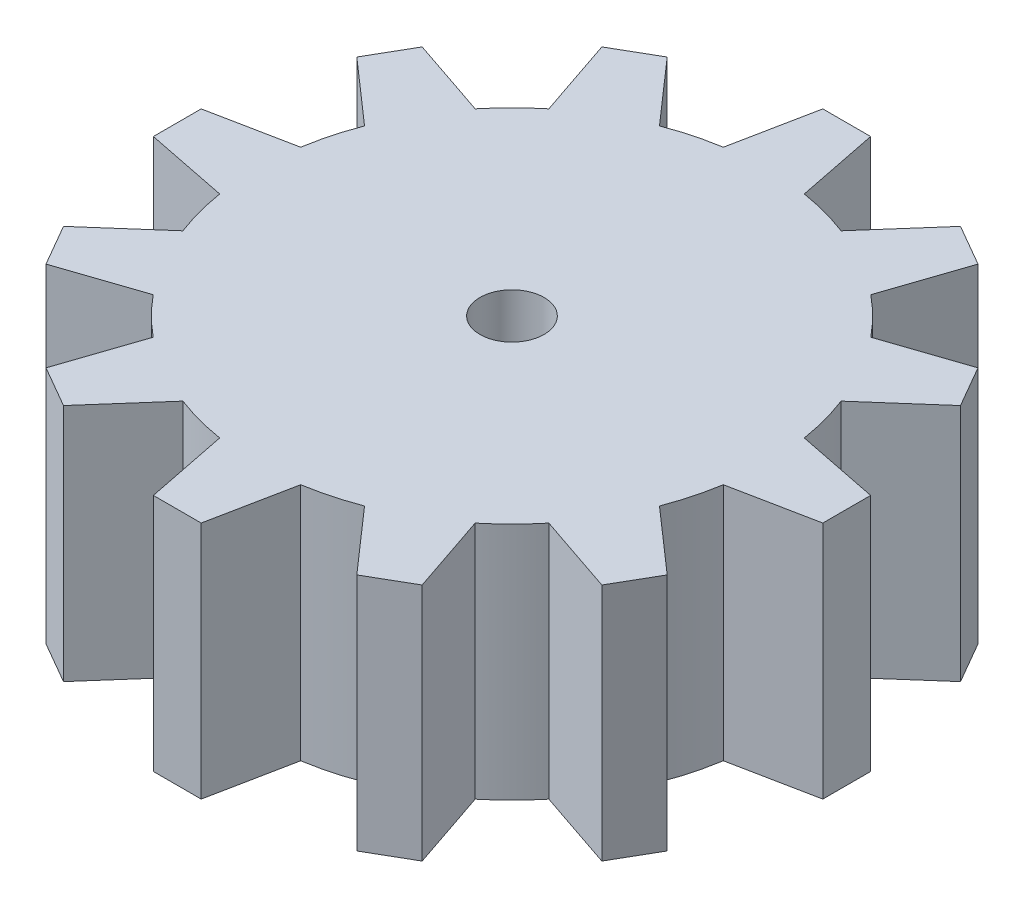
from build123d import *

# Parameters (mm, degrees)
BOSS_EXTRUDE1_DEPTH = 15
CUT_EXTRUDE1_REACH  = 17
SKETCH2_R           = 2.013136899


with BuildPart() as part:
    # Sketch1 → Boss-Extrude1 (new body)
    with BuildSketch(Plane(origin=(0, 0, 0), x_dir=(1, 0, 0), z_dir=(0, 1, 0))):
        with BuildLine():
            Line((-2.540599067, 15.797004665), (-1.5, 21))
            Line((-1.5, 21), (1.5, 21))
            Line((1.5, 21), (2.540599067, 15.797004665))
            ThreePointArc((2.540599067, 15.797004665), (4.141104722, 15.454813221), (5.698279, 14.950906877))
            Line((5.698279, 14.950906877), (9.200961894, 18.936533479))
            Line((9.200961894, 18.936533479), (11.799038106, 17.436533479))
            Line((11.799038106, 17.436533479), (10.098725665, 12.41030781))
            ThreePointArc((10.098725665, 12.41030781), (11.313708499, 11.313708499), (12.41030781, 10.098725665))
            Line((12.41030781, 10.098725665), (17.436533479, 11.799038106))
            Line((17.436533479, 11.799038106), (18.936533479, 9.200961894))
            Line((18.936533479, 9.200961894), (14.950906877, 5.698279))
            ThreePointArc((14.950906877, 5.698279), (15.454813221, 4.141104722), (15.797004665, 2.540599067))
            Line((15.797004665, 2.540599067), (21, 1.5))
            Line((21, 1.5), (21, -1.5))
            Line((21, -1.5), (15.797004665, -2.540599067))
            ThreePointArc((15.797004665, -2.540599067), (15.454813221, -4.141104722), (14.950906877, -5.698279))
            Line((14.950906877, -5.698279), (18.936533479, -9.200961894))
            Line((18.936533479, -9.200961894), (17.436533479, -11.799038106))
            Line((17.436533479, -11.799038106), (12.41030781, -10.098725665))
            ThreePointArc((12.41030781, -10.098725665), (11.313708499, -11.313708499), (10.098725665, -12.41030781))
            Line((10.098725665, -12.41030781), (11.799038106, -17.436533479))
            Line((11.799038106, -17.436533479), (9.200961894, -18.936533479))
            Line((9.200961894, -18.936533479), (5.698279, -14.950906877))
            ThreePointArc((5.698279, -14.950906877), (4.141104722, -15.454813221), (2.540599067, -15.797004665))
            Line((2.540599067, -15.797004665), (1.5, -21))
            Line((1.5, -21), (-1.5, -21))
            Line((-1.5, -21), (-2.540599067, -15.797004665))
            ThreePointArc((-2.540599067, -15.797004665), (-4.141104722, -15.454813221), (-5.698279, -14.950906877))
            Line((-5.698279, -14.950906877), (-9.200961894, -18.936533479))
            Line((-9.200961894, -18.936533479), (-11.799038106, -17.436533479))
            Line((-11.799038106, -17.436533479), (-10.098725665, -12.41030781))
            ThreePointArc((-10.098725665, -12.41030781), (-11.313708499, -11.313708499), (-12.41030781, -10.098725665))
            Line((-12.41030781, -10.098725665), (-17.436533479, -11.799038106))
            Line((-17.436533479, -11.799038106), (-18.936533479, -9.200961894))
            Line((-18.936533479, -9.200961894), (-14.950906877, -5.698279))
            ThreePointArc((-14.950906877, -5.698279), (-15.454813221, -4.141104722), (-15.797004665, -2.540599067))
            Line((-15.797004665, -2.540599067), (-21, -1.5))
            Line((-21, -1.5), (-21, 1.5))
            Line((-21, 1.5), (-15.797004665, 2.540599067))
            ThreePointArc((-15.797004665, 2.540599067), (-15.454813221, 4.141104722), (-14.950906877, 5.698279))
            Line((-14.950906877, 5.698279), (-18.936533479, 9.200961894))
            Line((-18.936533479, 9.200961894), (-17.436533479, 11.799038106))
            Line((-17.436533479, 11.799038106), (-12.41030781, 10.098725665))
            ThreePointArc((-12.41030781, 10.098725665), (-11.313708499, 11.313708499), (-10.098725665, 12.41030781))
            Line((-10.098725665, 12.41030781), (-11.799038106, 17.436533479))
            Line((-11.799038106, 17.436533479), (-9.200961894, 18.936533479))
            Line((-9.200961894, 18.936533479), (-5.698279, 14.950906877))
            ThreePointArc((-5.698279, 14.950906877), (-4.141104722, 15.454813221), (-2.540599067, 15.797004665))
        make_face()
    extrude(amount=BOSS_EXTRUDE1_DEPTH)

    # Sketch2 → Cut-Extrude1 (cut, up to next)
    with BuildSketch(Plane(origin=(0, 0, 0), x_dir=(1, 0, 0), z_dir=(0, 1, 0)), mode=Mode.PRIVATE) as cut_extrude1_sk1:
        Circle(SKETCH2_R)
    cut_extrude1_tool1 = extrude(cut_extrude1_sk1.sketch, amount=CUT_EXTRUDE1_REACH, mode=Mode.PRIVATE) & part.part
    add(cut_extrude1_tool1.solids().sort_by_distance((0, 0, 0))[0], mode=Mode.SUBTRACT)


solid = part.part
